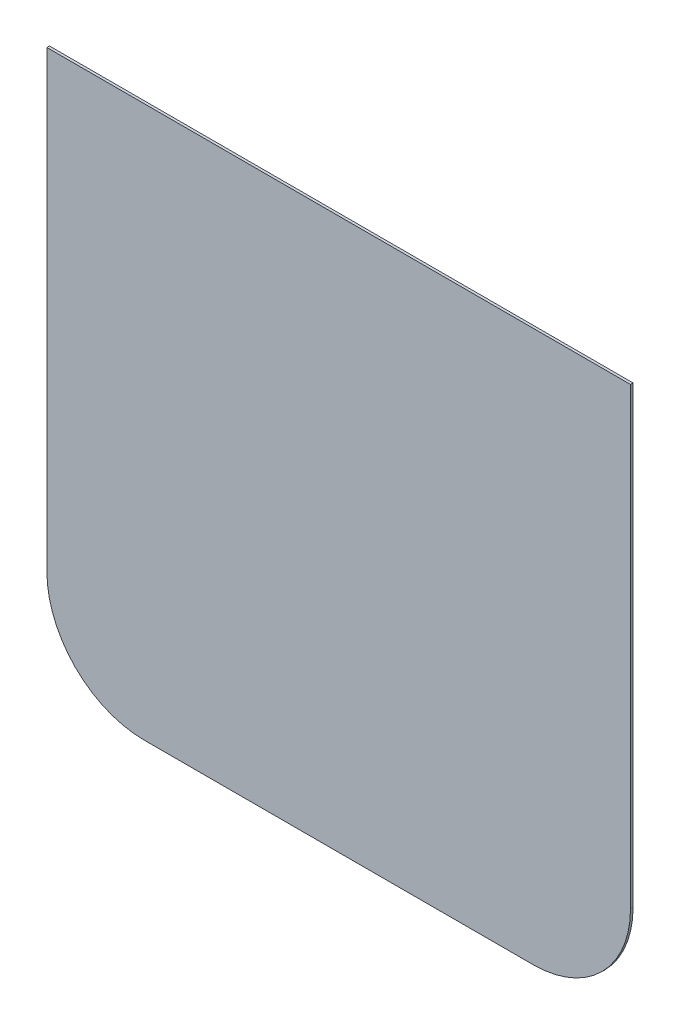
from build123d import *

# Parameters (mm, degrees)
EXTRUDE_2_DEPTH = 2


with BuildPart() as part:
    # Эскиз1 → Бобышка-Вытянуть2 (new body)
    with BuildSketch(Plane.XY):
        with BuildLine():
            Line((-260.93597277, 123.115577889), (-260.93597277, -226.884422111))
            ThreePointArc((-260.93597277, -226.884422111), (-238.968981359, -279.9174307), (-185.93597277, -301.884422111))
            Line((-185.93597277, -301.884422111), (114.06402723, -301.884422111))
            ThreePointArc((114.06402723, -301.884422111), (167.097035819, -279.9174307), (189.06402723, -226.884422111))
            Line((189.06402723, -226.884422111), (189.06402723, 123.115577889))
            Line((189.06402723, 123.115577889), (164.06402723, 123.115577889))
            Line((164.06402723, 123.115577889), (-260.93597277, 123.115577889))
        make_face()
    extrude(amount=EXTRUDE_2_DEPTH)


solid = part.part
